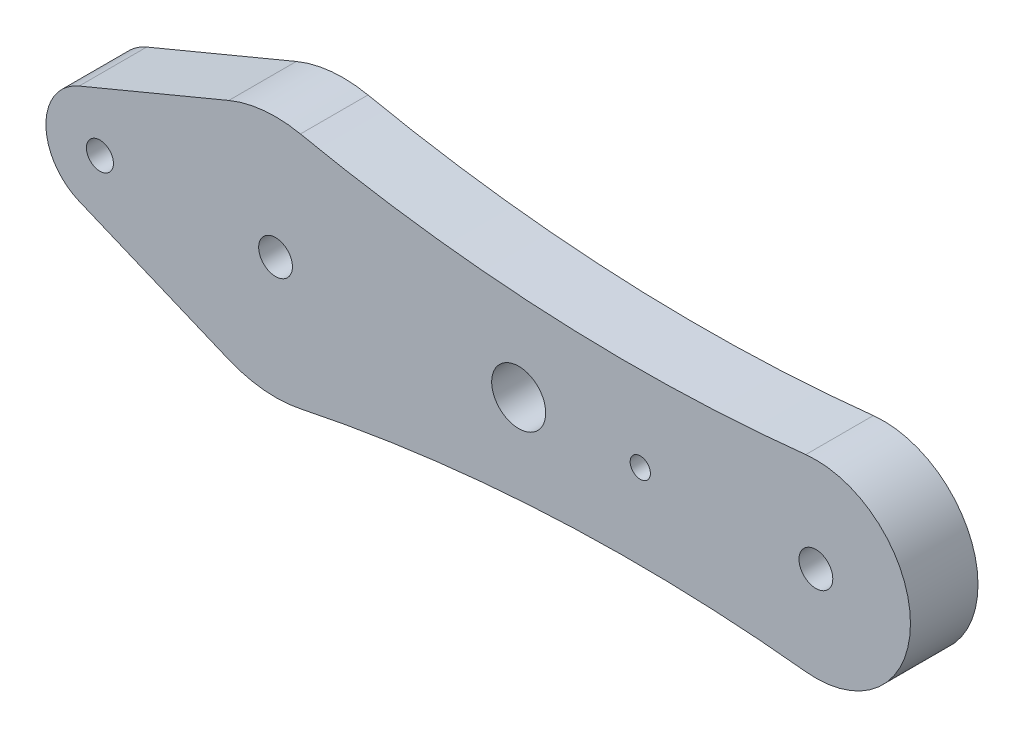
from build123d import *

# Parameters (mm, degrees)
SKETCH1_R           = 1.25
SKETCH1_R_2         = 1
SKETCH1_R_3         = 2
SKETCH1_R_4         = 0.75
BOSS_EXTRUDE1_DEPTH = 5


with BuildPart() as part:
    # Sketch1 → Boss-Extrude1 (new body)
    with BuildSketch(Plane.XY):
        with BuildLine():
            Line((-14.538461538, 3.692307692), (-3.461538462, 8.307692308))
            ThreePointArc((-3.461538462, 8.307692308), (-0.847818166, 8.959977922), (1.841860465, 8.809514744))
            ThreePointArc((1.841860465, 8.809514744), (20.473513899, 6.416147504), (39.250393701, 6.959747869))
            ThreePointArc((39.250393701, 6.959747869), (47, 0), (39.250393701, -6.959747869))
            ThreePointArc((39.250393701, -6.959747869), (20.473513899, -6.416147504), (1.841860465, -8.809514744))
            ThreePointArc((1.841860465, -8.809514744), (-0.847818166, -8.959977922), (-3.461538462, -8.307692308))
            Line((-3.461538462, -8.307692308), (-14.538461538, -3.692307692))
            ThreePointArc((-14.538461538, -3.692307692), (-17, 0), (-14.538461538, 3.692307692))
        make_face()
        Circle(SKETCH1_R, mode=Mode.SUBTRACT)
        with Locations((40, 0)):
            Circle(SKETCH1_R, mode=Mode.SUBTRACT)
        with Locations((-13, 0)):
            Circle(SKETCH1_R_2, mode=Mode.SUBTRACT)
        with Locations((18, 0)):
            Circle(SKETCH1_R_3, mode=Mode.SUBTRACT)
        with Locations((27, 0)):
            Circle(SKETCH1_R_4, mode=Mode.SUBTRACT)
    extrude(amount=BOSS_EXTRUDE1_DEPTH)


solid = part.part
